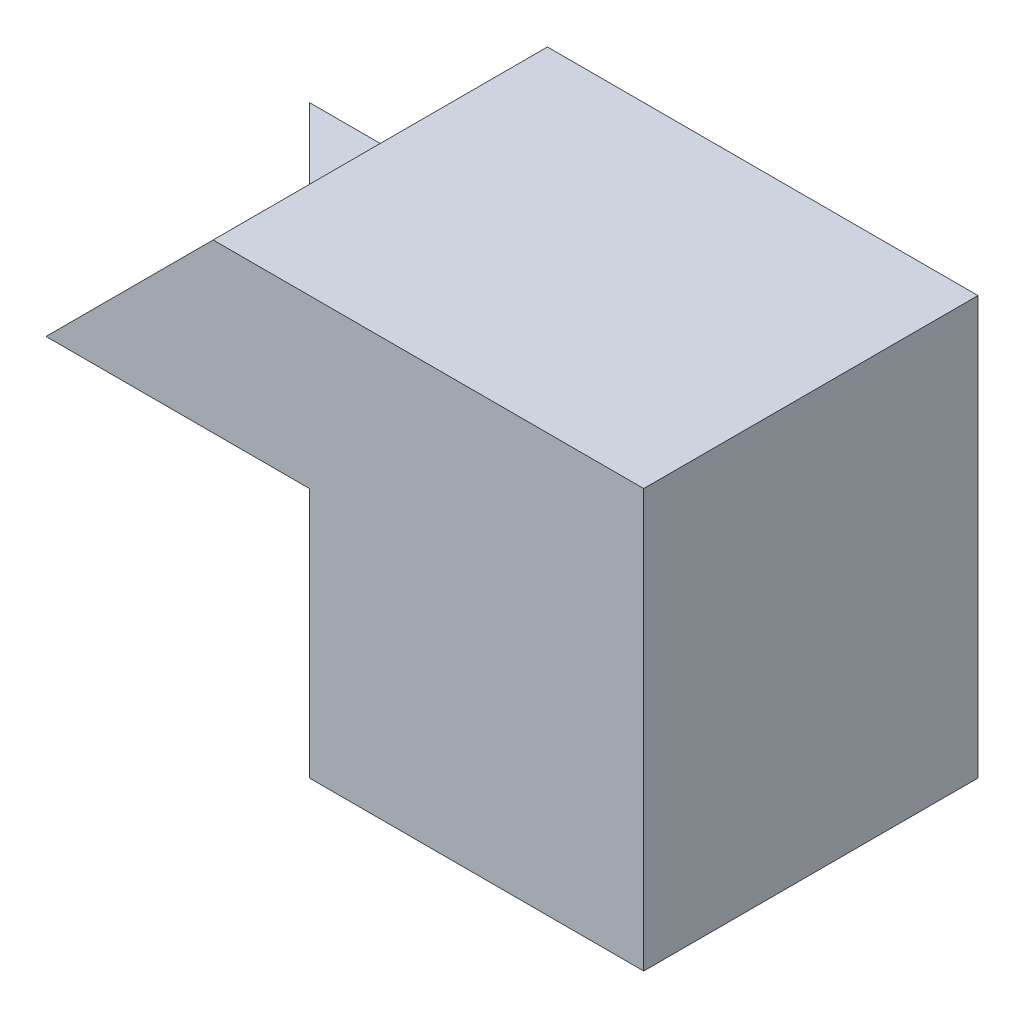
from build123d import *

# Parameters (mm, degrees)
BOSS_EXTRUDE1_DEPTH = 3
BOSS_EXTRUDE2_DEPTH = 4


with BuildPart() as part:
    # Sketch1 → Boss-Extrude1 (new body)
    with BuildSketch(Plane(origin=(0, 0, 0), x_dir=(1, 0, 0), z_dir=(0, 1, 0))):
        Polygon((0, 0), (-4, 4), (0, 4), align=None)
    extrude(amount=BOSS_EXTRUDE1_DEPTH)

    # Sketch2 → Boss-Extrude2 (add)
    with BuildSketch(Plane(origin=(0, 0, -4), x_dir=(-1, 0, 0), z_dir=(0, 0, -1))):
        Polygon((1.152291055, 5), (3.152291055, 3), (0, 3), (0, 0), (-4, 0), (-4, 5), align=None)
    extrude(amount=-BOSS_EXTRUDE2_DEPTH)


solid = part.part
